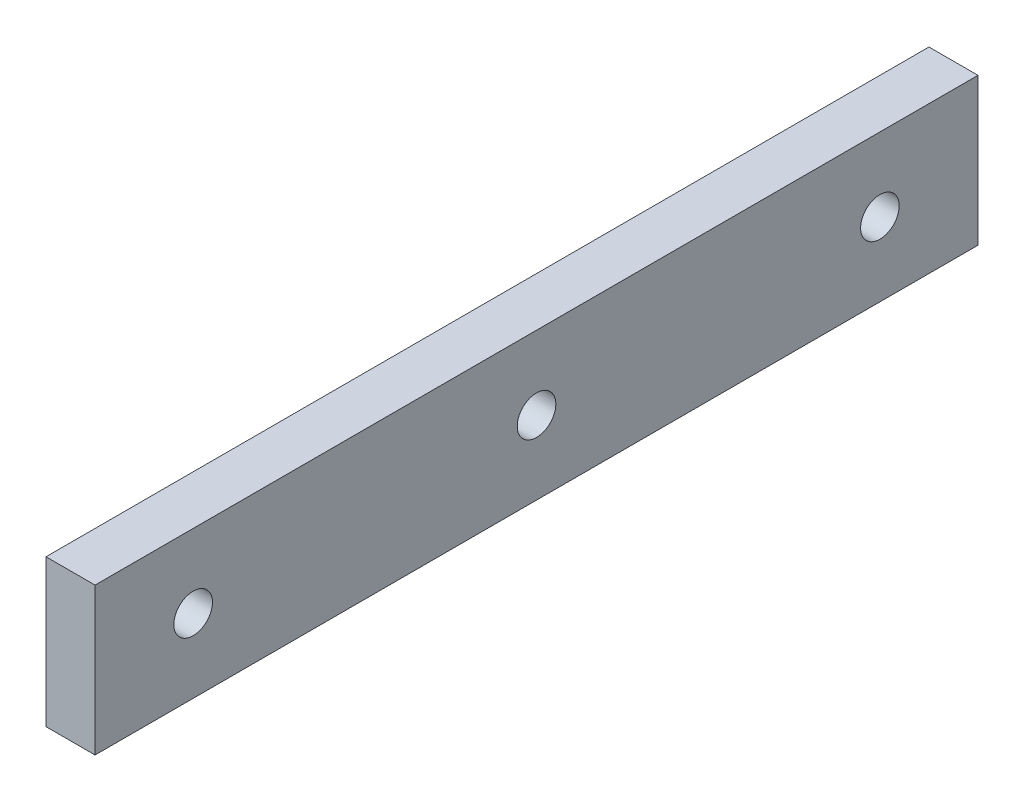
from build123d import *

# Parameters (mm, degrees)
SKETCH1_W                 = 6.35
SKETCH1_H                 = 19.05
EXTRUDE1_DEPTH            = 57.15
M6X1_0_TAPPED_HOLE1_D     = 5
M6X1_0_TAPPED_HOLE1_DEPTH = 6.35
M6X1_0_TAPPED_HOLE2_D     = 5


with BuildPart() as part:
    # Sketch1 → Extrude1 (new body, symmetric)
    with BuildSketch(Plane.XY):
        Rectangle(SKETCH1_W, SKETCH1_H)
    extrude(amount=EXTRUDE1_DEPTH, both=True)

    # M6x1.0 Tapped Hole1
    with Locations(Plane(origin=(3.175, 0, 0), x_dir=(0, 0, -1), z_dir=(1, 0, 0))):
        with Locations((-44.45, 0), (44.45, 0)):
            Hole(M6X1_0_TAPPED_HOLE1_D / 2, depth=M6X1_0_TAPPED_HOLE1_DEPTH)

    # M6x1.0 Tapped Hole2 (through all)
    with Locations(Plane(origin=(3.175, 0, 0), x_dir=(0, 0, -1), z_dir=(1, 0, 0))):
        with Locations((0, 0)):
            Hole(M6X1_0_TAPPED_HOLE2_D / 2)


solid = part.part
